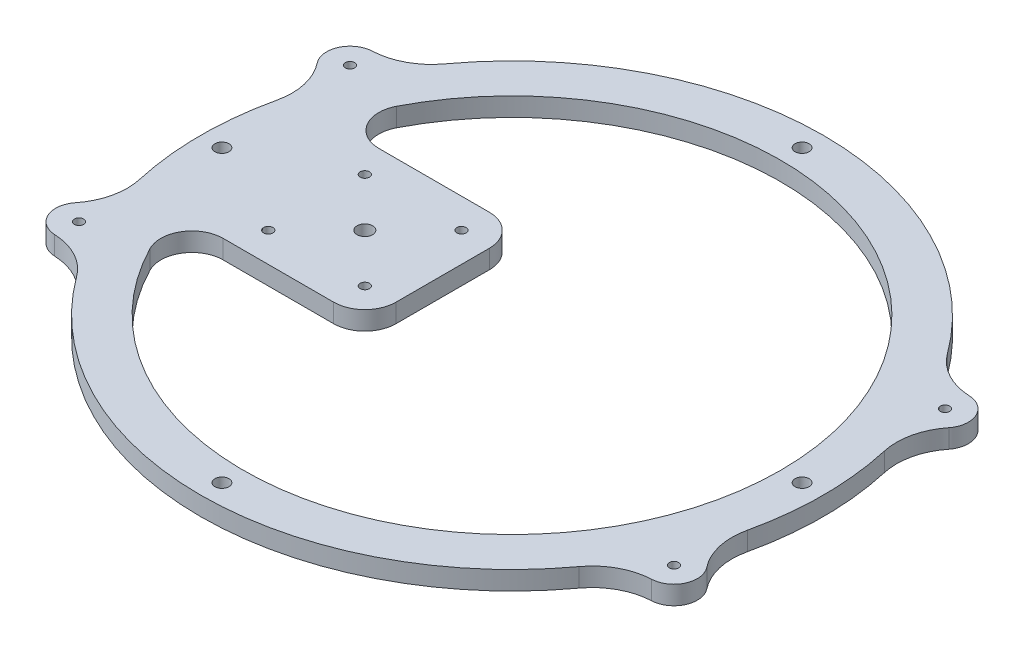
from build123d import *

# Parameters (mm, degrees)
SKETCH1_R           = 86.25
BOSS_EXTRUDE1_DEPTH = 6
SKETCH2_R           = 1.5
CUT_EXTRUDE1_DEPTH  = 6
SKETCH3_R           = 2.25
CUT_EXTRUDE2_DEPTH  = 6
CUT_EXTRUDE3_DEPTH  = 6
FILLET1_R           = 20
SKETCH5_R           = 2.5
SKETCH5_R_2         = 1.5
BOSS_EXTRUDE2_DEPTH = 6
FILLET2_R           = 10


with BuildPart() as part:
    # Sketch1 → Boss-Extrude1 (new body)
    with BuildSketch(Plane(origin=(0, 0, 0), x_dir=(1, 0, 0), z_dir=(0, 1, 0))):
        with BuildLine():
            Line((75.993420768, 65), (110, 65))
            Line((110, 65), (110, -65))
            Line((110, -65), (75.993420768, -65))
            ThreePointArc((75.993420768, -65), (0, -100), (-75.993420768, -65))
            Line((-75.993420768, -65), (-110, -65))
            Line((-110, -65), (-110, 65))
            Line((-110, 65), (-75.993420768, 65))
            ThreePointArc((-75.993420768, 65), (0, 100), (75.993420768, 65))
        make_face()
        Circle(SKETCH1_R, mode=Mode.SUBTRACT)
    extrude(amount=BOSS_EXTRUDE1_DEPTH)

    # Sketch2 → Cut-Extrude1 (cut)
    with BuildSketch(Plane(origin=(0, 0, 0), x_dir=(1, 0, 0), z_dir=(0, 1, 0))):
        with Locations((-95.5, 43.5)):
            Circle(SKETCH2_R)
        with Locations((95.5, 43.5)):
            Circle(SKETCH2_R)
        with Locations((95.5, -43.5)):
            Circle(SKETCH2_R)
        with Locations((-95.5, -43.5)):
            Circle(SKETCH2_R)
    extrude(amount=CUT_EXTRUDE1_DEPTH, mode=Mode.SUBTRACT)

    # Sketch3 → Cut-Extrude2 (cut)
    with BuildSketch(Plane(origin=(0, 0, 0), x_dir=(1, 0, 0), z_dir=(0, 1, 0))):
        with Locations((0, 93.125)):
            Circle(SKETCH3_R)
        with Locations((93.125, 0)):
            Circle(SKETCH3_R)
        with Locations((0, -93.125)):
            Circle(SKETCH3_R)
        with Locations((-93.125, 0)):
            Circle(SKETCH3_R)
    extrude(amount=CUT_EXTRUDE2_DEPTH, mode=Mode.SUBTRACT)

    # Sketch4 → Cut-Extrude3 (cut)
    with BuildSketch(Plane(origin=(0, 0, 0), x_dir=(1, 0, 0), z_dir=(0, 1, 0))):
        with BuildLine():
            Line((98.608905775, -36.674701114), (93.856581268, -34.510029742))
            ThreePointArc((93.856581268, -34.510029742), (100, 0), (93.856581268, 34.510029742))
            Line((93.856581268, 34.510029742), (98.608905775, 36.674701114))
            ThreePointArc((98.608905775, 36.674701114), (102.325298886, 46.608905775), (92.391094225, 50.325298886))
            Line((92.391094225, 50.325298886), (87.638769717, 48.160627513))
            ThreePointArc((87.638769717, 48.160627513), (82.248188777, 56.879130117), (75.993420768, 65))
            Line((75.993420768, 65), (110, 65))
            Line((110, 65), (110, -65))
            Line((110, -65), (75.993420768, -65))
            ThreePointArc((75.993420768, -65), (82.248188777, -56.879130117), (87.638769717, -48.160627513))
            Line((87.638769717, -48.160627513), (92.391094225, -50.325298886))
            ThreePointArc((92.391094225, -50.325298886), (102.325298886, -46.608905775), (98.608905775, -36.674701114))
        make_face()
        with BuildLine():
            Line((-98.608905775, 36.674701114), (-93.856581268, 34.510029742))
            ThreePointArc((-93.856581268, 34.510029742), (-100, 0), (-93.856581268, -34.510029742))
            Line((-93.856581268, -34.510029742), (-98.608905775, -36.674701114))
            ThreePointArc((-98.608905775, -36.674701114), (-102.325298886, -46.608905775), (-92.391094225, -50.325298886))
            Line((-92.391094225, -50.325298886), (-87.638769717, -48.160627513))
            ThreePointArc((-87.638769717, -48.160627513), (-82.248188777, -56.879130117), (-75.993420768, -65))
            Line((-75.993420768, -65), (-110, -65))
            Line((-110, -65), (-110, 65))
            Line((-110, 65), (-75.993420768, 65))
            ThreePointArc((-75.993420768, 65), (-82.248188777, 56.879130117), (-87.638769717, 48.160627513))
            Line((-87.638769717, 48.160627513), (-92.391094225, 50.325298886))
            ThreePointArc((-92.391094225, 50.325298886), (-102.325298886, 46.608905775), (-98.608905775, 36.674701114))
        make_face()
    extrude(amount=CUT_EXTRUDE3_DEPTH, mode=Mode.SUBTRACT)

    # Fillet1
    fillet1_edges = [part.edges().sort_by_distance(p)[0] for p in [
        (87.638769717, 3, -48.160627513),
        (93.856581268, 3, -34.510029742),
        (93.856581268, 3, 34.510029742),
        (87.638769717, 3, 48.160627513),
        (-87.638769717, 3, 48.160627513),
        (-93.856581268, 3, 34.510029742),
        (-93.856581268, 3, -34.510029742),
        (-87.638769717, 3, -48.160627513),
    ]]
    fillet(fillet1_edges, radius=FILLET1_R)

    # Sketch5 → Boss-Extrude2 (add)
    with BuildSketch(Plane(origin=(0, 0, 0), x_dir=(1, 0, 0), z_dir=(0, 1, 0))):
        Polygon((-72.25, 25), (-22.25, 25), (-22.25, -25), (-72.25, -25), (-87.689436508, -25), (-87.689436508, 25), align=None)
        with Locations((-47.25, 0)):
            Circle(SKETCH5_R, mode=Mode.SUBTRACT)
        with Locations((-62.75, 15.5)):
            Circle(SKETCH5_R_2, mode=Mode.SUBTRACT)
        with Locations((-31.75, 15.5)):
            Circle(SKETCH5_R_2, mode=Mode.SUBTRACT)
        with Locations((-62.75, -15.5)):
            Circle(SKETCH5_R_2, mode=Mode.SUBTRACT)
        with Locations((-31.75, -15.5)):
            Circle(SKETCH5_R_2, mode=Mode.SUBTRACT)
    extrude(amount=BOSS_EXTRUDE2_DEPTH)

    # Fillet2
    fillet2_edges = [part.edges().sort_by_distance(p)[0] for p in [
        (-82.547334905, 3, 25),
        (-82.547334905, 3, -25),
        (-22.25, 3, 25),
        (-22.25, 3, -25),
    ]]
    fillet(fillet2_edges, radius=FILLET2_R)


solid = part.part
